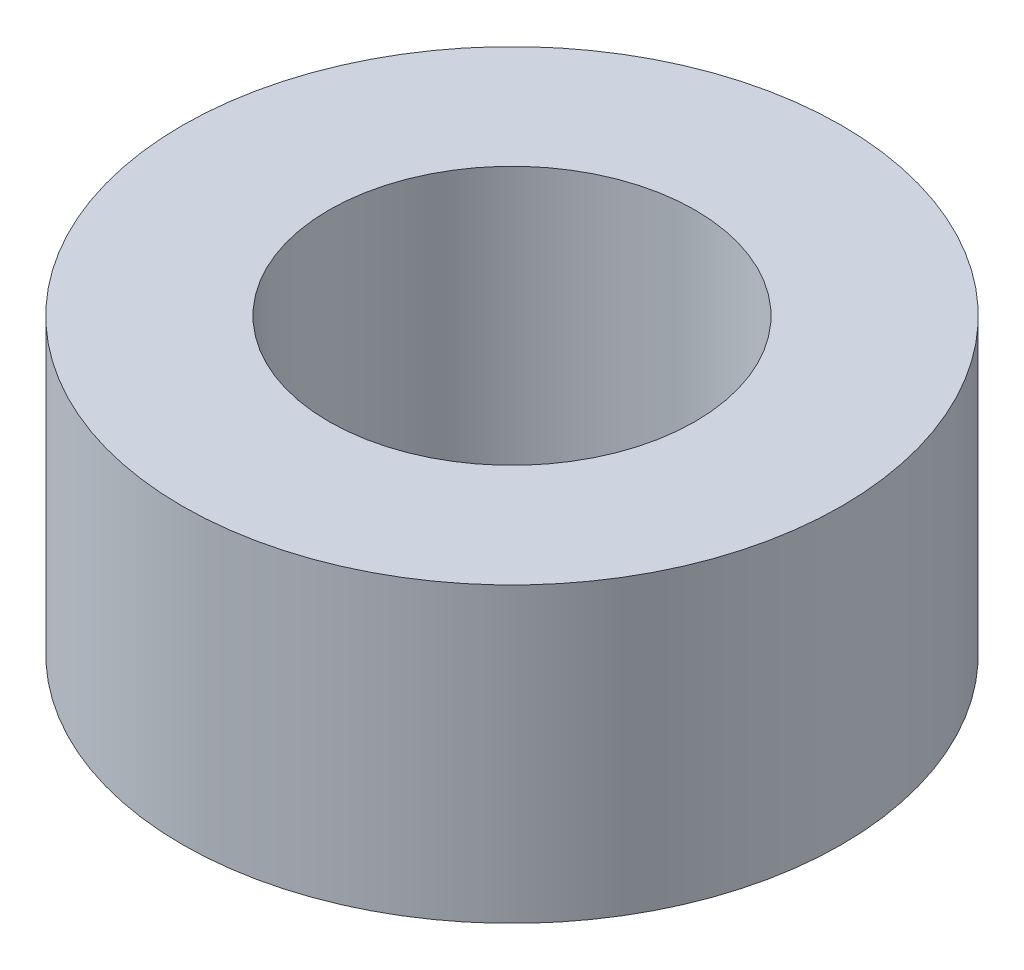
from build123d import *

# Parameters (mm, degrees)
SKETCH1_R           = 7.14375
SKETCH1_R_2         = 3.96875
BOSS_EXTRUDE1_DEPTH = 6.35


with BuildPart() as part:
    # Sketch1 → Boss-Extrude1 (new body)
    with BuildSketch(Plane(origin=(0, 0, 0), x_dir=(1, 0, 0), z_dir=(0, 1, 0))):
        Circle(SKETCH1_R)
        Circle(SKETCH1_R_2, mode=Mode.SUBTRACT)
    extrude(amount=BOSS_EXTRUDE1_DEPTH)


solid = part.part
